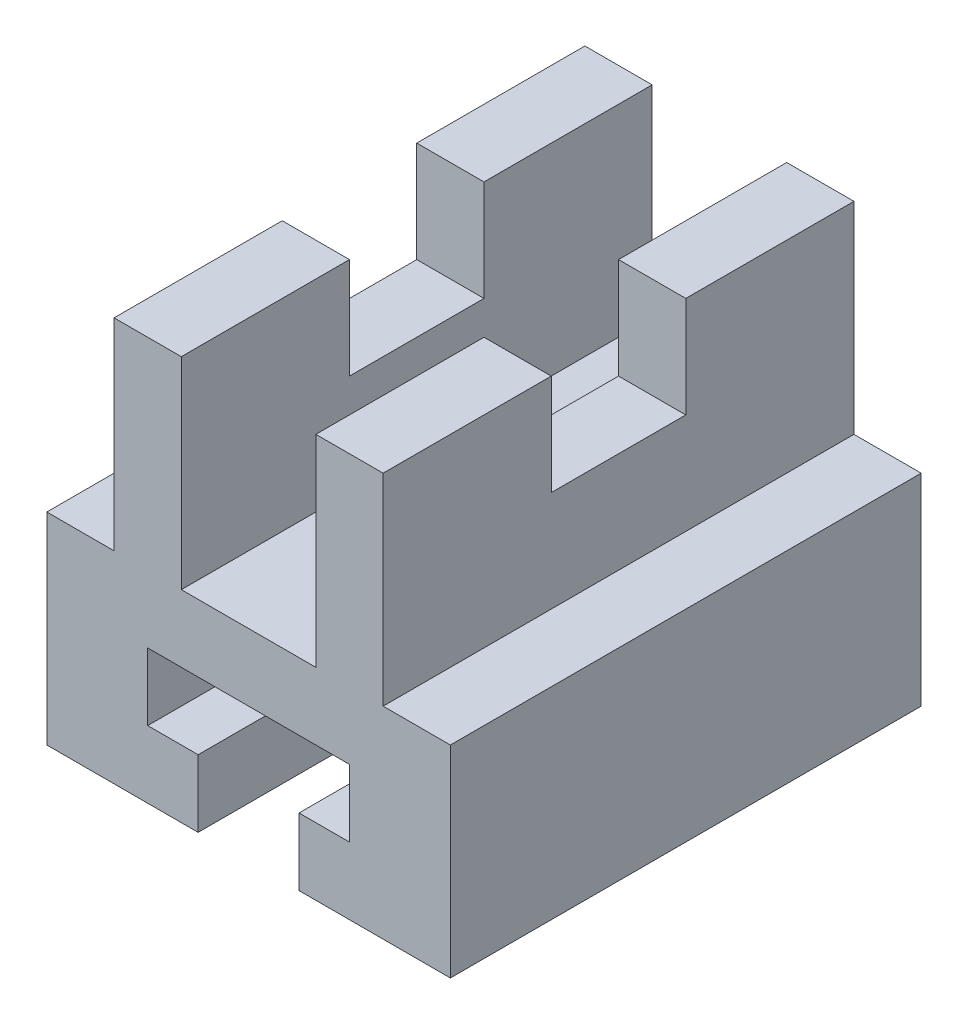
from build123d import *

# Parameters (mm, degrees)
IZIM1_W                     = 60
IZIM1_H                     = 60
Y_KSEKLIK_EKSTR_ZYON1_DEPTH = 70
KES_EKSTR_ZYON1_DEPTH       = 70
IZIM3_W                     = 10
IZIM3_H                     = 30
KES_EKSTR_ZYON2_DEPTH       = 70
IZIM4_W                     = 20
IZIM4_H                     = 30
KES_EKSTR_ZYON5_DEPTH       = 70
IZIM5_W                     = 20
IZIM5_H                     = 15
KES_EKSTR_ZYON6_DEPTH       = 40


with BuildPart() as part:
    # Çizim1 → Yükseklik-Ekstrüzyon1 (new body)
    with BuildSketch(Plane.XY):
        with Locations((-5.635360797, -4.69273743)):
            Rectangle(IZIM1_W, IZIM1_H)
    extrude(amount=Y_KSEKLIK_EKSTR_ZYON1_DEPTH)

    # Çizim2 → Kes-Ekstrüzyon1 (cut)
    with BuildSketch(Plane.XY.offset(70)):
        Polygon((9.364639203, -24.69273743), (1.864639203, -24.69273743), (1.864639203, -34.69273743), (-5.635360797, -34.69273743), (-13.135360797, -34.69273743), (-13.135360797, -24.69273743), (-20.635360797, -24.69273743), (-20.635360797, -14.69273743), (9.364639203, -14.69273743), align=None)
    extrude(amount=-KES_EKSTR_ZYON1_DEPTH, mode=Mode.SUBTRACT)

    # Çizim3 → Kes-Ekstrüzyon2 (cut)
    with BuildSketch(Plane.XY.offset(70)):
        with Locations((19.364639203, 10.30726257)):
            Rectangle(IZIM3_W, IZIM3_H)
        with Locations((-30.635360797, 10.30726257)):
            Rectangle(IZIM3_W, IZIM3_H)
    extrude(amount=-KES_EKSTR_ZYON2_DEPTH, mode=Mode.SUBTRACT)

    # Çizim4 → Kes-Ekstrüzyon5 (cut)
    with BuildSketch(Plane.XY.offset(70)):
        with Locations((-5.635360797, 10.30726257)):
            Rectangle(IZIM4_W, IZIM4_H)
    extrude(amount=-KES_EKSTR_ZYON5_DEPTH, mode=Mode.SUBTRACT)

    # Çizim5 → Kes-Ekstrüzyon6 (cut)
    with BuildSketch(Plane.ZY.offset(25.635360797)):
        with Locations((35, 17.80726257)):
            Rectangle(IZIM5_W, IZIM5_H)
    extrude(amount=-KES_EKSTR_ZYON6_DEPTH, mode=Mode.SUBTRACT)


solid = part.part
